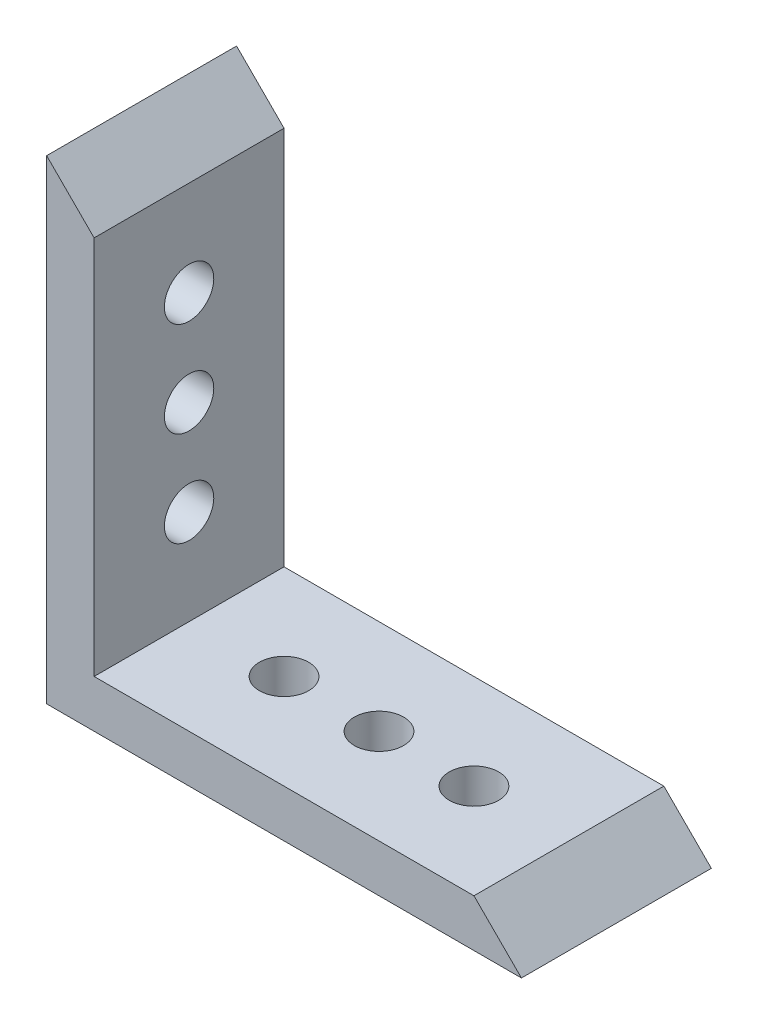
from build123d import *

# Parameters (mm, degrees)
BOSS_EXTRUDE1_DEPTH     = 20
CUT_EXTRUDE1_DEPTH      = 1
CUT_EXTRUDE1_DEPTH_BACK = 21
SKETCH4_R               = 2.6
CUT_EXTRUDE2_DEPTH      = 6
SKETCH5_R               = 2.6
CUT_EXTRUDE3_DEPTH      = 6


with BuildPart() as part:
    # Sketch1 → Boss-Extrude1 (new body)
    with BuildSketch(Plane.XY):
        Polygon((0, 0), (0, 50), (50, 0), align=None)
    extrude(amount=BOSS_EXTRUDE1_DEPTH)

    # Sketch2 → Cut-Extrude1 (cut, two sides)
    with BuildSketch(Plane.XY.offset(20)) as cut_extrude1_sk:
        Polygon((5, 182.279220614), (5, 45), (5, 5), (45, 5), (182.279220614, 5), (376.421356237, 199.142135624), (199.142135624, 376.421356237), align=None)
    extrude(amount=CUT_EXTRUDE1_DEPTH, mode=Mode.SUBTRACT)
    extrude(cut_extrude1_sk.sketch, amount=-CUT_EXTRUDE1_DEPTH_BACK, mode=Mode.SUBTRACT)

    # Sketch4 → Cut-Extrude2 (cut, through all)
    with BuildSketch(Plane(origin=(5, 0, 0), x_dir=(0, 0, -1), z_dir=(1, 0, 0))):
        with Locations((-10, 35)):
            Circle(SKETCH4_R)
        with Locations((-10, 25)):
            Circle(SKETCH4_R)
        with Locations((-10, 15)):
            Circle(SKETCH4_R)
    extrude(amount=-CUT_EXTRUDE2_DEPTH, mode=Mode.SUBTRACT)

    # Sketch5 → Cut-Extrude3 (cut, through all)
    with BuildSketch(Plane(origin=(0, 5, 0), x_dir=(1, 0, 0), z_dir=(0, 1, 0))):
        with Locations((35, -10)):
            Circle(SKETCH5_R)
        with Locations((25, -10)):
            Circle(SKETCH5_R)
        with Locations((15, -10)):
            Circle(SKETCH5_R)
    extrude(amount=-CUT_EXTRUDE3_DEPTH, mode=Mode.SUBTRACT)


solid = part.part
